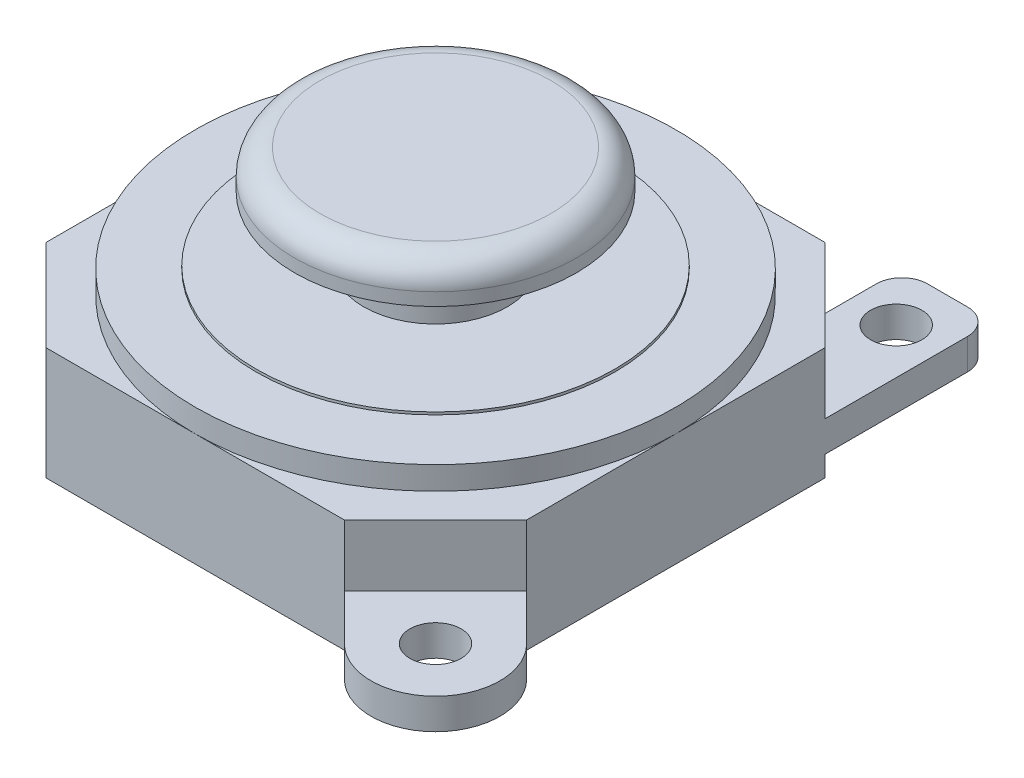
from build123d import *

# Parameters (mm, degrees)
BOSS_EXTRUDE1_DEPTH = 4.4
SKETCH2_R           = 9.375
BOSS_EXTRUDE2_DEPTH = 0.9
SKETCH3_R           = 7
BOSS_EXTRUDE3_DEPTH = 0.1
SKETCH4_R           = 2.8
BOSS_EXTRUDE4_DEPTH = 2.5
SKETCH5_R           = 5.5
BOSS_EXTRUDE5_DEPTH = 1.5
FILLET1_R           = 1
BOSS_EXTRUDE6_START = -0.8
BOSS_EXTRUDE6_DEPTH = 1.2
SKETCH7_R           = 1
BOSS_EXTRUDE7_DEPTH = 1.2


with BuildPart() as part:
    # Sketch1 → Boss-Extrude1 (new body)
    with BuildSketch(Plane(origin=(-40.787368979, -82.87971859, -2.365032328), x_dir=(1, 0, 0), z_dir=(0, 1, 0))):
        Polygon((28.025105958, 37.98255848), (31.581105958, 34.42655848), (31.581105958, 22.78855848), (28.025105958, 19.23255848), (16.387105958, 19.23255848), (12.831105958, 22.78855848), (12.831105958, 34.42655848), (16.387105958, 37.98255848), align=None)
    extrude(amount=BOSS_EXTRUDE1_DEPTH)

    # Sketch2 → Boss-Extrude2 (add)
    with BuildSketch(Plane(origin=(0, -78.47971859, 0), x_dir=(1, 0, 0), z_dir=(0, 1, 0))):
        with Locations(Location((-18.581263021, 30.972590809, 0), (0, 0, 270))):
            Circle(SKETCH2_R)
    extrude(amount=BOSS_EXTRUDE2_DEPTH)

    # Sketch3 → Boss-Extrude3 (add)
    with BuildSketch(Plane(origin=(0, -77.57971859, 0), x_dir=(1, 0, 0), z_dir=(0, 1, 0))):
        with Locations(Location((-18.581263021, 30.972590809, 0), (0, 0, 270))):
            Circle(SKETCH3_R)
    extrude(amount=BOSS_EXTRUDE3_DEPTH)

    # Sketch4 → Boss-Extrude4 (add)
    with BuildSketch(Plane(origin=(0, -77.47971859, 0), x_dir=(1, 0, 0), z_dir=(0, 1, 0))):
        with Locations(Location((-18.581263021, 30.972590809, 0), (0, 0, 270))):
            Circle(SKETCH4_R)
    extrude(amount=BOSS_EXTRUDE4_DEPTH)

    # Sketch5 → Boss-Extrude5 (add)
    with BuildSketch(Plane(origin=(0, -74.97971859, 0), x_dir=(1, 0, 0), z_dir=(0, 1, 0))):
        with Locations(Location((-18.581263021, 30.972590809, 0), (0, 0, 270))):
            Circle(SKETCH5_R)
    extrude(amount=BOSS_EXTRUDE5_DEPTH)

    # Fillet1
    fillet1_edges = [part.edges().sort_by_distance(p)[0] for p in [
        (-18.581263021, -73.47971859, -36.472590809),
    ]]
    fillet(fillet1_edges, radius=FILLET1_R)

    # Sketch6 → Boss-Extrude6 (add)
    with BuildSketch(Plane.XZ.offset(82.87971859).offset(BOSS_EXTRUDE6_START)):
        with BuildLine():
            ThreePointArc((-6.691791307, -21.597590809), (-8.244016355, -19.274521857), (-10.984263021, -19.819590809))
            Line((-10.984263021, -19.819590809), (-9.913369802, -20.890484027))
            ThreePointArc((-9.913369802, -20.890484027), (-8.823579589, -20.673711276), (-8.206263021, -21.597590809))
            ThreePointArc((-8.206263021, -21.597590809), (-8.282383489, -21.980274241), (-8.49915624, -22.30469759))
            Line((-8.49915624, -22.30469759), (-7.428263021, -23.375590809))
            ThreePointArc((-7.428263021, -23.375590809), (-6.88319407, -22.559837475), (-6.691791307, -21.597590809))
        make_face()
        with BuildLine():
            Line((-9.913369802, -20.890484027), (-10.984263021, -19.819590809))
            ThreePointArc((-10.984263021, -19.819590809), (-11.720734735, -21.597590809), (-10.984263021, -23.375590809))
            ThreePointArc((-10.984263021, -23.375590809), (-9.206263021, -24.112062522), (-7.428263021, -23.375590809))
            Line((-7.428263021, -23.375590809), (-8.49915624, -22.30469759))
            ThreePointArc((-8.49915624, -22.30469759), (-9.913369802, -22.30469759), (-9.913369802, -20.890484027))
        make_face()
        with BuildLine():
            Line((-10.984263021, -19.819590809), (-12.762263021, -21.597590809))
            Line((-12.762263021, -21.597590809), (-10.984263021, -23.375590809))
            ThreePointArc((-10.984263021, -23.375590809), (-11.720734735, -21.597590809), (-10.984263021, -19.819590809))
        make_face()
        with BuildLine():
            ThreePointArc((-7.428263021, -23.375590809), (-9.206263021, -24.112062522), (-10.984263021, -23.375590809))
            Line((-10.984263021, -23.375590809), (-9.206263021, -25.153590809))
            Line((-9.206263021, -25.153590809), (-7.428263021, -23.375590809))
        make_face()
    extrude(amount=-BOSS_EXTRUDE6_DEPTH)

    # Sketch7 → Boss-Extrude7 (add)
    with BuildSketch(Plane.XZ.offset(82.07971859)):
        with BuildLine():
            Line((-9.206263021, -36.791590809), (-9.206263021, -42.347590809))
            ThreePointArc((-9.206263021, -42.347590809), (-9.49915624, -43.05469759), (-10.206263021, -43.347590809))
            Line((-10.206263021, -43.347590809), (-11.762263021, -43.347590809))
            ThreePointArc((-11.762263021, -43.347590809), (-12.469369802, -43.05469759), (-12.762263021, -42.347590809))
            Line((-12.762263021, -42.347590809), (-12.762263021, -40.347590809))
            Line((-12.762263021, -40.347590809), (-9.206263021, -36.791590809))
        make_face()
        with Locations(Location((-10.984263021, -41.347590809, 0), (0, 0, 270))):
            Circle(SKETCH7_R, mode=Mode.SUBTRACT)
    extrude(amount=-BOSS_EXTRUDE7_DEPTH)


solid = part.part
